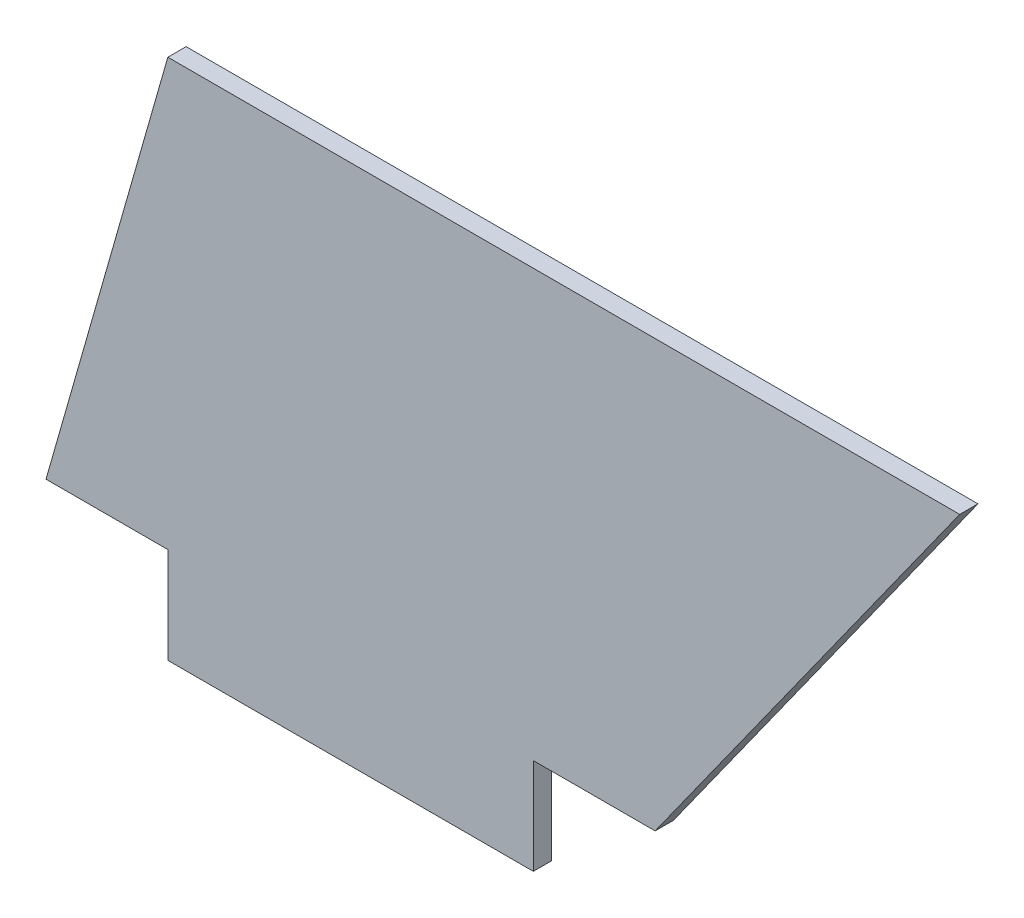
from build123d import *

# Parameters (mm, degrees)
BOSS_EXTRUDE1_DEPTH = 1.5


with BuildPart() as part:
    # Sketch1 → Boss-Extrude1 (new body)
    with BuildSketch(Plane.XY):
        Polygon((0, 0), (10, 0), (10, -7.875), (40, -7.875), (40, 0), (50, 0), (75, 35), (10, 35), align=None)
    extrude(amount=BOSS_EXTRUDE1_DEPTH)


solid = part.part
